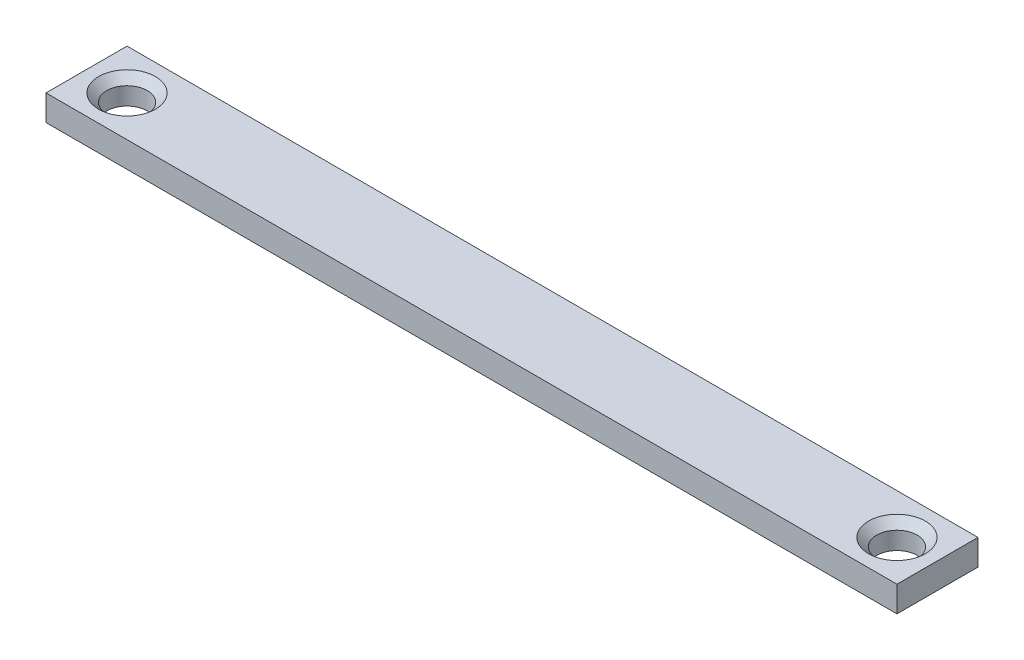
from build123d import *

# Parameters (mm, degrees)
SKETCH1_W                      = 105
SKETCH1_H                      = 10
BOSS_EXTRUDE1_DEPTH            = 3.175
M6X1_0_TAPPED_HOLE1_AT_2_COUNT = 2
M6X1_0_TAPPED_HOLE1_AT_2_PITCH = 95


with BuildPart() as part:
    # Sketch1 → Boss-Extrude1 (new body)
    with BuildSketch(Plane(origin=(0, 0, 0), x_dir=(1, 0, 0), z_dir=(0, 1, 0))):
        Rectangle(SKETCH1_W, SKETCH1_H)
    extrude(amount=BOSS_EXTRUDE1_DEPTH)

    # Sketch4 → M6x1.0 Tapped Hole1 (revolve, cut)
    with BuildSketch(Plane(origin=(47.5, 3.175, 0), x_dir=(0, 0, 1), z_dir=(1, 0, 0))):
        Polygon((0, 0), (0, 3.175), (2.5, 3.175), (2.5, 1), (3.5, 0), align=None)
    m6x1_0_tapped_hole1 = revolve(axis=Axis((47.5, 9.525, 0), (0, -1, 0)), mode=Mode.SUBTRACT)

    # M6x1.0 Tapped Hole1 at 2: M6x1.0 Tapped Hole1 ×2
    with Locations(*[(-i * M6X1_0_TAPPED_HOLE1_AT_2_PITCH, 0, 0) for i in range(1, M6X1_0_TAPPED_HOLE1_AT_2_COUNT)]):
        add(m6x1_0_tapped_hole1, mode=Mode.SUBTRACT)


solid = part.part
